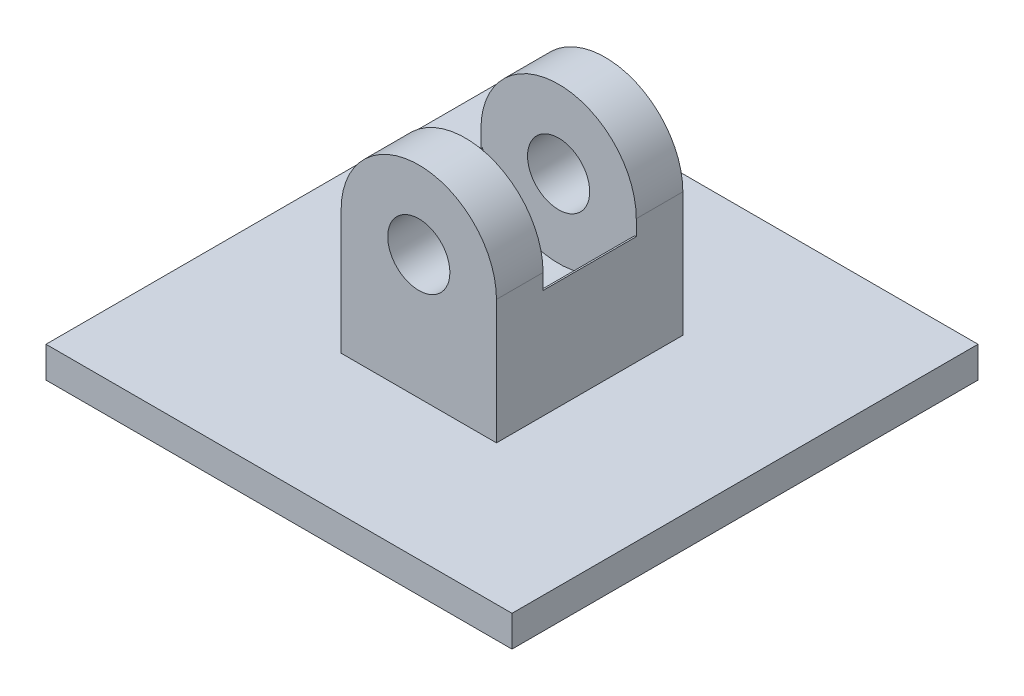
from build123d import *

# Parameters (mm, degrees)
SKETCH1_W           = 150
SKETCH1_H           = 150
BOSS_EXTRUDE1_DEPTH = 10
SKETCH2_W           = 50
SKETCH2_H           = 60
BOSS_EXTRUDE2_DEPTH = 40
BOSS_EXTRUDE3_DEPTH = 60
SKETCH4_R           = 10
CUT_EXTRUDE1_DEPTH  = 60
SKETCH5_W           = 30
SKETCH5_H           = 30
CUT_EXTRUDE2_DEPTH  = 50
SKETCH6_R           = 25
CUT_EXTRUDE3_DEPTH  = 30


with BuildPart() as part:
    # Sketch1 → Boss-Extrude1 (new body)
    with BuildSketch(Plane(origin=(0, 0, 0), x_dir=(1, 0, 0), z_dir=(0, 1, 0))):
        Rectangle(SKETCH1_W, SKETCH1_H)
    extrude(amount=BOSS_EXTRUDE1_DEPTH)

    # Sketch2 → Boss-Extrude2 (add)
    with BuildSketch(Plane(origin=(0, 10, 0), x_dir=(1, 0, 0), z_dir=(0, 1, 0))):
        Rectangle(SKETCH2_W, SKETCH2_H)
    extrude(amount=BOSS_EXTRUDE2_DEPTH)

    # Sketch3 → Boss-Extrude3 (add)
    with BuildSketch(Plane.XY.offset(30)):
        with BuildLine():
            Line((-25, 50), (25, 50))
            ThreePointArc((25, 50), (0, 75), (-25, 50))
        make_face()
    extrude(amount=-BOSS_EXTRUDE3_DEPTH)

    # Sketch4 → Cut-Extrude1 (cut)
    with BuildSketch(Plane.XY.offset(30)):
        with Locations((0, 50)):
            Circle(SKETCH4_R)
    extrude(amount=-CUT_EXTRUDE1_DEPTH, mode=Mode.SUBTRACT)

    # Sketch5 → Cut-Extrude2 (cut)
    with BuildSketch(Plane.ZY.offset(25)):
        with Locations((0, 60)):
            Rectangle(SKETCH5_W, SKETCH5_H)
    extrude(amount=-CUT_EXTRUDE2_DEPTH, mode=Mode.SUBTRACT)

    # Sketch6 → Cut-Extrude3 (cut)
    with BuildSketch(Plane.XY.offset(-15)):
        with Locations((0, 50)):
            Circle(SKETCH6_R)
    extrude(amount=CUT_EXTRUDE3_DEPTH, mode=Mode.SUBTRACT)


solid = part.part
